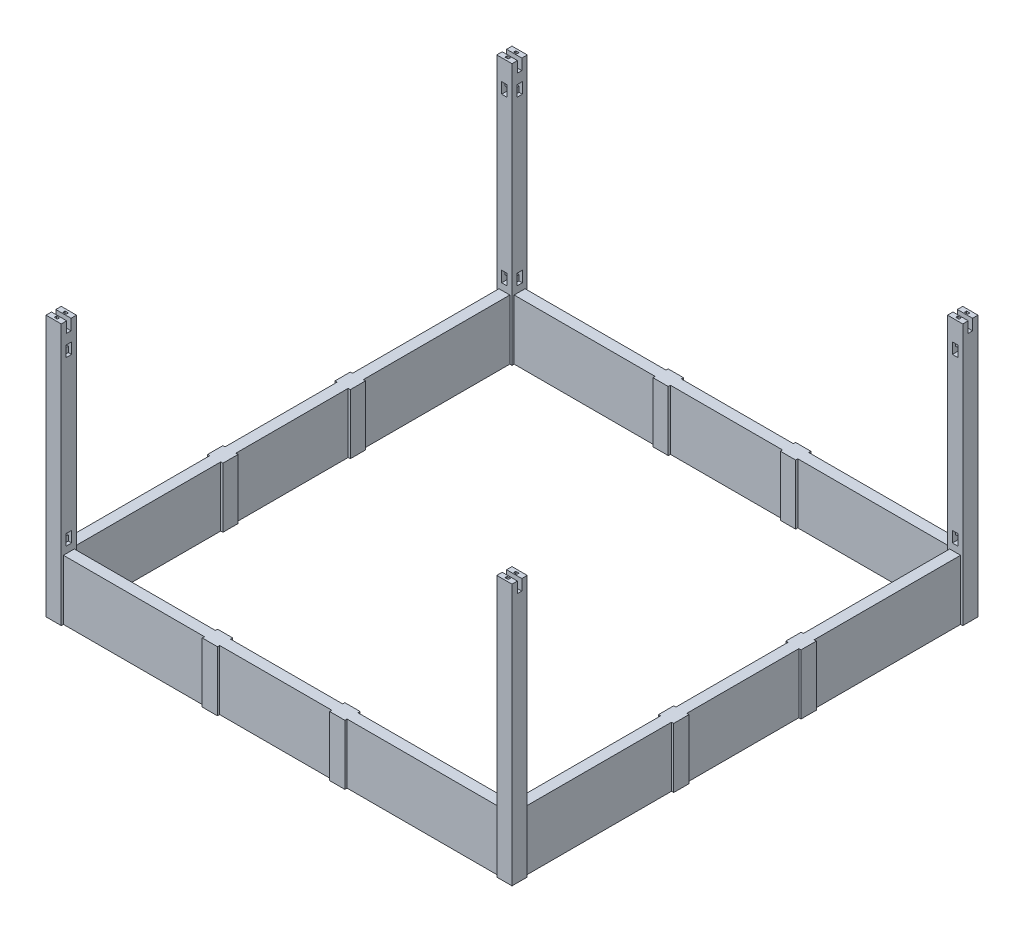
from build123d import *

# Parameters (mm, degrees)
SKETCH_1_W                  = 140
SKETCH_1_H                  = 140
EXTRUDE_1_DEPTH             = 2400
EXTRUDE_1_2_DEPTH           = 2400
EXTRUDE_1_3_DEPTH           = 2400
EXTRUDE_1_4_DEPTH           = 2400
SKETCH_2_W                  = 40
SKETCH_2_H                  = 100
CUT_EXTRUDE_1_DEPTH         = 100
PATTERN_LINEAR_1_COUNT      = 2
PATTERN_LINEAR_1_PITCH      = 4140
PATTERN_LINEAR_1_COUNT_DIR2 = 2
PATTERN_LINEAR_1_PITCH_DIR2 = 4140
SKETCH_3_W                  = 100
SKETCH_3_H                  = 550
EXTRUDE_2_DEPTH             = 4000
PATTERN_LINEAR_2_COUNT      = 2
PATTERN_LINEAR_2_PITCH      = 4140
SKETCH_4_W                  = 100
SKETCH_4_H                  = 550
EXTRUDE_3_DEPTH             = 4000
PATTERN_LINEAR_4_COUNT      = 2
PATTERN_LINEAR_4_PITCH      = 4140
SKETCH_5_W                  = 140
SKETCH_5_H                  = 140
EXTRUDE_4_DEPTH             = 550
SKETCH_6_W                  = 40
SKETCH_6_H                  = 100
CUT_EXTRUDE_2_DEPTH         = 100
PATTERN_LINEAR_5_COUNT      = 2
PATTERN_LINEAR_5_PITCH      = 1170
PATTERN_LINEAR_5_COUNT_DIR2 = 2
PATTERN_LINEAR_5_PITCH_DIR2 = 4140
SKETCH_8_W                  = 140
SKETCH_8_H                  = 140
SKETCH_8_W_2                = 100
SKETCH_8_H_2                = 40
EXTRUDE_5_DEPTH             = 550
SKETCH_10_W                 = 100
SKETCH_10_H                 = 40
CUT_EXTRUDE_3_DEPTH         = 100
PATTERN_LINEAR_6_COUNT      = 2
PATTERN_LINEAR_6_PITCH      = 1170
PATTERN_LINEAR_6_COUNT_DIR2 = 2
PATTERN_LINEAR_6_PITCH_DIR2 = 4140
SKETCH_11_W                 = 140
SKETCH_11_H                 = 40
CUT_EXTRUDE_4_DEPTH         = 100
PATTERN_LINEAR_7_COUNT      = 2
PATTERN_LINEAR_7_PITCH      = 4140
PATTERN_LINEAR_7_COUNT_DIR2 = 2
PATTERN_LINEAR_7_PITCH_DIR2 = 4140
SKETCH_12_W                 = 30
SKETCH_12_H                 = 20
CUT_EXTRUDE_5_DEPTH         = 50
PATTERN_LINEAR_8_COUNT      = 2
PATTERN_LINEAR_8_PITCH      = 4140
PATTERN_LINEAR_8_COUNT_DIR2 = 2
PATTERN_LINEAR_8_PITCH_DIR2 = 4140
SKETCH_13_W                 = 50
SKETCH_13_H                 = 100
CUT_EXTRUDE_6_DEPTH         = 30
SKETCH_14_W                 = 50
SKETCH_14_H                 = 50
CUT_EXTRUDE_7_DEPTH         = 50
PATTERN_LINEAR_9_COUNT      = 2
PATTERN_LINEAR_9_PITCH      = 1500
MIRROR_1_COPY_1_SKETCH_W    = 50
MIRROR_1_COPY_1_SKETCH_H    = 100
MIRROR_1_COPY_1_DEPTH       = 30
MIRROR_1_COPY_2_SKETCH_W    = 50
MIRROR_1_COPY_2_SKETCH_H    = 50
MIRROR_1_COPY_2_DEPTH       = 50
MIRROR_2_COPY_1_SKETCH_W    = 50
MIRROR_2_COPY_1_SKETCH_H    = 100
MIRROR_2_COPY_1_DEPTH       = 30
MIRROR_2_COPY_2_SKETCH_W    = 50
MIRROR_2_COPY_2_SKETCH_H    = 50
MIRROR_2_COPY_2_DEPTH       = 50
MIRROR_2_COPY_3_SKETCH_W    = 50
MIRROR_2_COPY_3_SKETCH_H    = 100
MIRROR_2_COPY_3_DEPTH       = 30
MIRROR_2_COPY_4_SKETCH_W    = 50
MIRROR_2_COPY_4_SKETCH_H    = 50
MIRROR_2_COPY_4_DEPTH       = 50
MIRROR_2_COPY_5_SKETCH_W    = 50
MIRROR_2_COPY_5_SKETCH_H    = 100
MIRROR_2_COPY_5_DEPTH       = 30
MIRROR_2_COPY_6_SKETCH_W    = 50
MIRROR_2_COPY_6_SKETCH_H    = 50
MIRROR_2_COPY_6_DEPTH       = 50
SKETCH_15_W                 = 50
SKETCH_15_H                 = 100
CUT_EXTRUDE_8_DEPTH         = 30
SKETCH_16_W                 = 50
SKETCH_16_H                 = 50
CUT_EXTRUDE_9_DEPTH         = 50
PATTERN_LINEAR_10_COUNT     = 2
PATTERN_LINEAR_10_PITCH     = 1500
MIRROR_3_COPY_1_SKETCH_W    = 50
MIRROR_3_COPY_1_SKETCH_H    = 100
MIRROR_3_COPY_1_DEPTH       = 30
MIRROR_3_COPY_2_SKETCH_W    = 50
MIRROR_3_COPY_2_SKETCH_H    = 50
MIRROR_3_COPY_2_DEPTH       = 50
MIRROR_4_COPY_1_SKETCH_W    = 50
MIRROR_4_COPY_1_SKETCH_H    = 100
MIRROR_4_COPY_1_DEPTH       = 30
MIRROR_4_COPY_2_SKETCH_W    = 50
MIRROR_4_COPY_2_SKETCH_H    = 50
MIRROR_4_COPY_2_DEPTH       = 50
MIRROR_4_COPY_3_SKETCH_W    = 50
MIRROR_4_COPY_3_SKETCH_H    = 100
MIRROR_4_COPY_3_DEPTH       = 30
MIRROR_4_COPY_4_SKETCH_W    = 50
MIRROR_4_COPY_4_SKETCH_H    = 50
MIRROR_4_COPY_4_DEPTH       = 50
MIRROR_4_COPY_5_SKETCH_W    = 50
MIRROR_4_COPY_5_SKETCH_H    = 100
MIRROR_4_COPY_5_DEPTH       = 30
MIRROR_4_COPY_6_SKETCH_W    = 50
MIRROR_4_COPY_6_SKETCH_H    = 50
MIRROR_4_COPY_6_DEPTH       = 50


with BuildPart() as part:
    # 草图1 → 凸台-拉伸1 (new body)
    with BuildSketch(Plane(origin=(0, 0, 0), x_dir=(1, 0, 0), z_dir=(0, 1, 0))):
        with Locations((70, 4210)):
            Rectangle(SKETCH_1_W, SKETCH_1_H)
    extrude(amount=EXTRUDE_1_DEPTH)


with BuildPart() as body_2:
    # 草图1 → Extrude 1 2 (new body)
    with BuildSketch(Plane(origin=(0, 0, 0), x_dir=(1, 0, 0), z_dir=(0, 1, 0))):
        with Locations((4210, 4210)):
            Rectangle(SKETCH_1_W, SKETCH_1_H)
    extrude(amount=EXTRUDE_1_2_DEPTH)


with BuildPart() as body_3:
    # 草图1 → Extrude 1 3 (new body)
    with BuildSketch(Plane(origin=(0, 0, 0), x_dir=(1, 0, 0), z_dir=(0, 1, 0))):
        with Locations((4210, 70)):
            Rectangle(SKETCH_1_W, SKETCH_1_H)
    extrude(amount=EXTRUDE_1_3_DEPTH)


with BuildPart() as body_4:
    # 草图1 → Extrude 1 4 (new body)
    with BuildSketch(Plane(origin=(0, 0, 0), x_dir=(1, 0, 0), z_dir=(0, 1, 0))):
        with Locations((70, 70)):
            Rectangle(SKETCH_1_W, SKETCH_1_H)
    extrude(amount=EXTRUDE_1_4_DEPTH)

    # 草图2 → 切除-拉伸1 (cut)
    with BuildSketch(Plane.XZ):
        with Locations((70, -70)):
            Rectangle(SKETCH_2_W, SKETCH_2_H)
    cut_extrude_1 = extrude(amount=-CUT_EXTRUDE_1_DEPTH, mode=Mode.SUBTRACT)


with BuildPart() as pattern_linear_1_tool:
    # 阵列(线性)1: Cut-Extrude 1 2 × 2
    with Locations(*[(i * PATTERN_LINEAR_1_PITCH, 0, -j * PATTERN_LINEAR_1_PITCH_DIR2) for i in range(PATTERN_LINEAR_1_COUNT) for j in range(PATTERN_LINEAR_1_COUNT_DIR2) if (i, j) != (0, 0)]):
        add(cut_extrude_1)


with BuildPart() as part_1:
    add(part.part)

    # 阵列(线性)1: cut by pattern_linear_1_tool
    add(pattern_linear_1_tool.part, mode=Mode.SUBTRACT)


with BuildPart() as body_2_1:
    add(body_2.part)

    # 阵列(线性)1: cut by pattern_linear_1_tool
    add(pattern_linear_1_tool.part, mode=Mode.SUBTRACT)


with BuildPart() as body_3_1:
    add(body_3.part)

    # 阵列(线性)1: cut by pattern_linear_1_tool
    add(pattern_linear_1_tool.part, mode=Mode.SUBTRACT)


    add(body_4.part)  # 凸台-拉伸2 merges body 4
    # 草图3 → 凸台-拉伸2 (add)
    with BuildSketch(Plane(origin=(140, 0, 0), x_dir=(0, 0, -1), z_dir=(1, 0, 0))):
        with Locations((70, 275)):
            Rectangle(SKETCH_3_W, SKETCH_3_H)
    extrude_2 = extrude(amount=EXTRUDE_2_DEPTH)


with BuildPart() as part_2:
    add(part_1.part)

    add(body_2_1.part)  # 阵列(线性)2 merges body 2
    # 阵列(线性)2: 凸台-拉伸2 ×2
    with Locations(*[(0, 0, -i * PATTERN_LINEAR_2_PITCH) for i in range(1, PATTERN_LINEAR_2_COUNT)]):
        add(extrude_2)

    add(body_3_1.part)  # 凸台-拉伸3 merges body 3
    # 草图4 → 凸台-拉伸3 (add)
    with BuildSketch(Plane(origin=(0, 0, -140), x_dir=(-1, 0, 0), z_dir=(0, 0, -1))):
        with Locations((-70, 275)):
            Rectangle(SKETCH_4_W, SKETCH_4_H)
    extrude_3 = extrude(amount=EXTRUDE_3_DEPTH)

    # 阵列(线性)4: 凸台-拉伸3 ×2
    with Locations(*[(i * PATTERN_LINEAR_4_PITCH, 0, 0) for i in range(1, PATTERN_LINEAR_4_COUNT)]):
        add(extrude_3)

    # 草图5 → 凸台-拉伸4 (add)
    with BuildSketch(Plane.XZ):
        with Locations((70, -1555)):
            Rectangle(SKETCH_5_W, SKETCH_5_H)
    extrude_4 = extrude(amount=-EXTRUDE_4_DEPTH)

    # 草图6 → 切除-拉伸2 (cut)
    with BuildSketch(Plane.XZ):
        with Locations((70, -1555)):
            Rectangle(SKETCH_6_W, SKETCH_6_H)
    cut_extrude_2 = extrude(amount=-CUT_EXTRUDE_2_DEPTH, mode=Mode.SUBTRACT)

    # 阵列(线性)5: 凸台-拉伸4, Cut-Extrude 2 2 × 2
    with Locations(*[(j * PATTERN_LINEAR_5_PITCH_DIR2, 0, -i * PATTERN_LINEAR_5_PITCH) for i in range(PATTERN_LINEAR_5_COUNT) for j in range(PATTERN_LINEAR_5_COUNT_DIR2) if (i, j) != (0, 0)]):
        add(extrude_4)
        add(cut_extrude_2, mode=Mode.SUBTRACT)

    # 草图8 → 凸台-拉伸5 (add)
    with BuildSketch(Plane.XZ):
        with Locations((1505, -70)):
            Rectangle(SKETCH_8_W, SKETCH_8_H)
        with Locations((1505, -70)):
            Rectangle(SKETCH_8_W_2, SKETCH_8_H_2, mode=Mode.SUBTRACT)
    extrude_5 = extrude(amount=-EXTRUDE_5_DEPTH)

    # 草图10 → 切除-拉伸3 (cut)
    with BuildSketch(Plane.XZ):
        with Locations((1505, -70)):
            Rectangle(SKETCH_10_W, SKETCH_10_H)
    cut_extrude_3 = extrude(amount=-CUT_EXTRUDE_3_DEPTH, mode=Mode.SUBTRACT)

    # 阵列(线性)6: 凸台-拉伸5, Cut-Extrude 3 2 × 2
    with Locations(*[(i * PATTERN_LINEAR_6_PITCH, 0, -j * PATTERN_LINEAR_6_PITCH_DIR2) for i in range(PATTERN_LINEAR_6_COUNT) for j in range(PATTERN_LINEAR_6_COUNT_DIR2) if (i, j) != (0, 0)]):
        add(extrude_5)
        add(cut_extrude_3, mode=Mode.SUBTRACT)

    # 草图11 → 切除-拉伸4 (cut)
    with BuildSketch(Plane(origin=(0, 2400, 0), x_dir=(1, 0, 0), z_dir=(0, 1, 0))):
        with Locations((70, 70)):
            Rectangle(SKETCH_11_W, SKETCH_11_H)
    cut_extrude_4 = extrude(amount=-CUT_EXTRUDE_4_DEPTH, mode=Mode.SUBTRACT)

    # 阵列(线性)7: Cut-Extrude 4 2 × 2
    with Locations(*[(i * PATTERN_LINEAR_7_PITCH, 0, -j * PATTERN_LINEAR_7_PITCH_DIR2) for i in range(PATTERN_LINEAR_7_COUNT) for j in range(PATTERN_LINEAR_7_COUNT_DIR2) if (i, j) != (0, 0)]):
        add(cut_extrude_4, mode=Mode.SUBTRACT)

    # 草图12 → 切除-拉伸5 (cut)
    with BuildSketch(Plane(origin=(0, 2400, 0), x_dir=(1, 0, 0), z_dir=(0, 1, 0))):
        with Locations((4210, 110)):
            Rectangle(SKETCH_12_W, SKETCH_12_H)
        with Locations((4210, 30)):
            Rectangle(SKETCH_12_W, SKETCH_12_H)
    cut_extrude_5 = extrude(amount=-CUT_EXTRUDE_5_DEPTH, mode=Mode.SUBTRACT)

    # 阵列(线性)8: Cut-Extrude 5 2 × 2
    with Locations(*[(-j * PATTERN_LINEAR_8_PITCH_DIR2, 0, -i * PATTERN_LINEAR_8_PITCH) for i in range(PATTERN_LINEAR_8_COUNT) for j in range(PATTERN_LINEAR_8_COUNT_DIR2) if (i, j) != (0, 0)]):
        add(cut_extrude_5, mode=Mode.SUBTRACT)

    # 草图13 → 切除-拉伸6 (cut)
    with BuildSketch(Plane(origin=(140, 0, 0), x_dir=(0, 0, -1), z_dir=(1, 0, 0))):
        with Locations((70, 660)):
            Rectangle(SKETCH_13_W, SKETCH_13_H)
    cut_extrude_6 = extrude(amount=-CUT_EXTRUDE_6_DEPTH, mode=Mode.SUBTRACT)

    # 草图14 → 切除-拉伸7 (cut)
    with BuildSketch(Plane(origin=(110, 0, 0), x_dir=(0, 0, -1), z_dir=(1, 0, 0))):
        with Locations((70, 685)):
            Rectangle(SKETCH_14_W, SKETCH_14_H)
    cut_extrude_7 = extrude(amount=-CUT_EXTRUDE_7_DEPTH, mode=Mode.SUBTRACT)

    # 阵列(线性)9: 切除-拉伸6, 切除-拉伸7 ×2
    with Locations(*[(0, i * PATTERN_LINEAR_9_PITCH, 0) for i in range(1, PATTERN_LINEAR_9_COUNT)]):
        add(cut_extrude_6, mode=Mode.SUBTRACT)
        add(cut_extrude_7, mode=Mode.SUBTRACT)

    # 镜向1: 切除-拉伸6, 切除-拉伸7 across plane
    add(cut_extrude_6.mirror(Plane(origin=(2140, 0, 0), x_dir=(0, 0, 1), z_dir=(1, 0, 0))), mode=Mode.SUBTRACT)
    add(cut_extrude_7.mirror(Plane(origin=(2140, 0, 0), x_dir=(0, 0, 1), z_dir=(1, 0, 0))), mode=Mode.SUBTRACT)

    # 镜向1 copy 1 sketch → 镜向1 copy 1 (cut)
    with BuildSketch(Plane(origin=(4140, 1500, 0), x_dir=(0, 0, -1), z_dir=(-1, 0, 0))):
        with Locations((70, -660)):
            Rectangle(MIRROR_1_COPY_1_SKETCH_W, MIRROR_1_COPY_1_SKETCH_H)
    extrude(amount=-MIRROR_1_COPY_1_DEPTH, mode=Mode.SUBTRACT)

    # 镜向1 copy 2 sketch → 镜向1 copy 2 (cut)
    with BuildSketch(Plane(origin=(4170, 1500, 0), x_dir=(0, 0, -1), z_dir=(-1, 0, 0))):
        with Locations((70, -685)):
            Rectangle(MIRROR_1_COPY_2_SKETCH_W, MIRROR_1_COPY_2_SKETCH_H)
    extrude(amount=-MIRROR_1_COPY_2_DEPTH, mode=Mode.SUBTRACT)

    # 镜向2: 切除-拉伸6, 切除-拉伸7 across plane
    add(cut_extrude_6.mirror(Plane.XY.offset(-2140)), mode=Mode.SUBTRACT)
    add(cut_extrude_7.mirror(Plane.XY.offset(-2140)), mode=Mode.SUBTRACT)

    # 镜向2 copy 1 sketch → 镜向2 copy 1 (cut)
    with BuildSketch(Plane(origin=(4140, 0, -4280), x_dir=(0, 0, 1), z_dir=(-1, 0, 0))):
        with Locations((70, 660)):
            Rectangle(MIRROR_2_COPY_1_SKETCH_W, MIRROR_2_COPY_1_SKETCH_H)
    extrude(amount=-MIRROR_2_COPY_1_DEPTH, mode=Mode.SUBTRACT)

    # 镜向2 copy 2 sketch → 镜向2 copy 2 (cut)
    with BuildSketch(Plane(origin=(4170, 0, -4280), x_dir=(0, 0, 1), z_dir=(-1, 0, 0))):
        with Locations((70, 685)):
            Rectangle(MIRROR_2_COPY_2_SKETCH_W, MIRROR_2_COPY_2_SKETCH_H)
    extrude(amount=-MIRROR_2_COPY_2_DEPTH, mode=Mode.SUBTRACT)

    # 镜向2 copy 3 sketch → 镜向2 copy 3 (cut)
    with BuildSketch(Plane(origin=(4140, 1500, -4280), x_dir=(0, 0, 1), z_dir=(-1, 0, 0))):
        with Locations((70, 660)):
            Rectangle(MIRROR_2_COPY_3_SKETCH_W, MIRROR_2_COPY_3_SKETCH_H)
    extrude(amount=-MIRROR_2_COPY_3_DEPTH, mode=Mode.SUBTRACT)

    # 镜向2 copy 4 sketch → 镜向2 copy 4 (cut)
    with BuildSketch(Plane(origin=(4170, 1500, -4280), x_dir=(0, 0, 1), z_dir=(-1, 0, 0))):
        with Locations((70, 685)):
            Rectangle(MIRROR_2_COPY_4_SKETCH_W, MIRROR_2_COPY_4_SKETCH_H)
    extrude(amount=-MIRROR_2_COPY_4_DEPTH, mode=Mode.SUBTRACT)

    # 镜向2 copy 5 sketch → 镜向2 copy 5 (cut)
    with BuildSketch(Plane(origin=(140, 1500, -4280), x_dir=(0, 0, 1), z_dir=(1, 0, 0))):
        with Locations((70, -660)):
            Rectangle(MIRROR_2_COPY_5_SKETCH_W, MIRROR_2_COPY_5_SKETCH_H)
    extrude(amount=-MIRROR_2_COPY_5_DEPTH, mode=Mode.SUBTRACT)

    # 镜向2 copy 6 sketch → 镜向2 copy 6 (cut)
    with BuildSketch(Plane(origin=(110, 1500, -4280), x_dir=(0, 0, 1), z_dir=(1, 0, 0))):
        with Locations((70, -685)):
            Rectangle(MIRROR_2_COPY_6_SKETCH_W, MIRROR_2_COPY_6_SKETCH_H)
    extrude(amount=-MIRROR_2_COPY_6_DEPTH, mode=Mode.SUBTRACT)

    # 草图15 → 切除-拉伸8 (cut)
    with BuildSketch(Plane(origin=(0, 0, -140), x_dir=(-1, 0, 0), z_dir=(0, 0, -1))):
        with Locations((-70, 660)):
            Rectangle(SKETCH_15_W, SKETCH_15_H)
    cut_extrude_8 = extrude(amount=-CUT_EXTRUDE_8_DEPTH, mode=Mode.SUBTRACT)

    # 草图16 → 切除-拉伸9 (cut)
    with BuildSketch(Plane(origin=(0, 0, -110), x_dir=(-1, 0, 0), z_dir=(0, 0, -1))):
        with Locations((-70, 635)):
            Rectangle(SKETCH_16_W, SKETCH_16_H)
    cut_extrude_9 = extrude(amount=-CUT_EXTRUDE_9_DEPTH, mode=Mode.SUBTRACT)

    # 阵列(线性)10: 切除-拉伸8, 切除-拉伸9 ×2
    with Locations(*[(0, i * PATTERN_LINEAR_10_PITCH, 0) for i in range(1, PATTERN_LINEAR_10_COUNT)]):
        add(cut_extrude_8, mode=Mode.SUBTRACT)
        add(cut_extrude_9, mode=Mode.SUBTRACT)

    # 镜向3: 切除-拉伸8, 切除-拉伸9 across plane
    add(cut_extrude_8.mirror(Plane.XY.offset(-2140)), mode=Mode.SUBTRACT)
    add(cut_extrude_9.mirror(Plane.XY.offset(-2140)), mode=Mode.SUBTRACT)

    # 镜向3 copy 1 sketch → 镜向3 copy 1 (cut)
    with BuildSketch(Plane(origin=(0, 1500, -4140), x_dir=(-1, 0, 0), z_dir=(0, 0, 1))):
        with Locations((-70, -660)):
            Rectangle(MIRROR_3_COPY_1_SKETCH_W, MIRROR_3_COPY_1_SKETCH_H)
    extrude(amount=-MIRROR_3_COPY_1_DEPTH, mode=Mode.SUBTRACT)

    # 镜向3 copy 2 sketch → 镜向3 copy 2 (cut)
    with BuildSketch(Plane(origin=(0, 1500, -4170), x_dir=(-1, 0, 0), z_dir=(0, 0, 1))):
        with Locations((-70, -635)):
            Rectangle(MIRROR_3_COPY_2_SKETCH_W, MIRROR_3_COPY_2_SKETCH_H)
    extrude(amount=-MIRROR_3_COPY_2_DEPTH, mode=Mode.SUBTRACT)

    # 镜向4: 切除-拉伸8, 切除-拉伸9 across plane
    add(cut_extrude_8.mirror(Plane(origin=(2140, 0, 0), x_dir=(0, 0, 1), z_dir=(1, 0, 0))), mode=Mode.SUBTRACT)
    add(cut_extrude_9.mirror(Plane(origin=(2140, 0, 0), x_dir=(0, 0, 1), z_dir=(1, 0, 0))), mode=Mode.SUBTRACT)

    # 镜向4 copy 1 sketch → 镜向4 copy 1 (cut)
    with BuildSketch(Plane(origin=(4280, 0, -4140), x_dir=(1, 0, 0), z_dir=(0, 0, 1))):
        with Locations((-70, 660)):
            Rectangle(MIRROR_4_COPY_1_SKETCH_W, MIRROR_4_COPY_1_SKETCH_H)
    extrude(amount=-MIRROR_4_COPY_1_DEPTH, mode=Mode.SUBTRACT)

    # 镜向4 copy 2 sketch → 镜向4 copy 2 (cut)
    with BuildSketch(Plane(origin=(4280, 0, -4170), x_dir=(1, 0, 0), z_dir=(0, 0, 1))):
        with Locations((-70, 635)):
            Rectangle(MIRROR_4_COPY_2_SKETCH_W, MIRROR_4_COPY_2_SKETCH_H)
    extrude(amount=-MIRROR_4_COPY_2_DEPTH, mode=Mode.SUBTRACT)

    # 镜向4 copy 3 sketch → 镜向4 copy 3 (cut)
    with BuildSketch(Plane(origin=(4280, 1500, -4140), x_dir=(1, 0, 0), z_dir=(0, 0, 1))):
        with Locations((-70, 660)):
            Rectangle(MIRROR_4_COPY_3_SKETCH_W, MIRROR_4_COPY_3_SKETCH_H)
    extrude(amount=-MIRROR_4_COPY_3_DEPTH, mode=Mode.SUBTRACT)

    # 镜向4 copy 4 sketch → 镜向4 copy 4 (cut)
    with BuildSketch(Plane(origin=(4280, 1500, -4170), x_dir=(1, 0, 0), z_dir=(0, 0, 1))):
        with Locations((-70, 635)):
            Rectangle(MIRROR_4_COPY_4_SKETCH_W, MIRROR_4_COPY_4_SKETCH_H)
    extrude(amount=-MIRROR_4_COPY_4_DEPTH, mode=Mode.SUBTRACT)

    # 镜向4 copy 5 sketch → 镜向4 copy 5 (cut)
    with BuildSketch(Plane(origin=(4280, 1500, -140), x_dir=(1, 0, 0), z_dir=(0, 0, -1))):
        with Locations((-70, -660)):
            Rectangle(MIRROR_4_COPY_5_SKETCH_W, MIRROR_4_COPY_5_SKETCH_H)
    extrude(amount=-MIRROR_4_COPY_5_DEPTH, mode=Mode.SUBTRACT)

    # 镜向4 copy 6 sketch → 镜向4 copy 6 (cut)
    with BuildSketch(Plane(origin=(4280, 1500, -110), x_dir=(1, 0, 0), z_dir=(0, 0, -1))):
        with Locations((-70, -635)):
            Rectangle(MIRROR_4_COPY_6_SKETCH_W, MIRROR_4_COPY_6_SKETCH_H)
    extrude(amount=-MIRROR_4_COPY_6_DEPTH, mode=Mode.SUBTRACT)


solid = part_2.part
